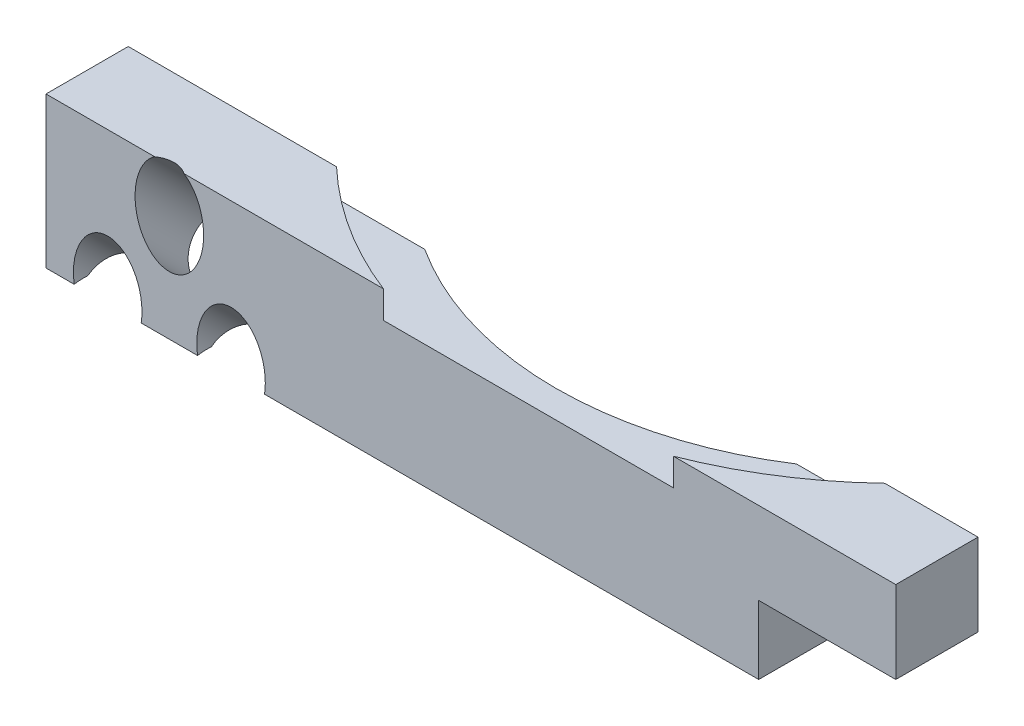
from build123d import *

# Parameters (mm, degrees)
SKETCH_1_W          = 70.4
SKETCH_1_H          = 11
EXTRUDE_1_DEPTH     = 6
CUT_EXTRUDE_1_DEPTH = 6.5
CUT_EXTRUDE_3_DEPTH = 17
CUT_EXTRUDE_4_DEPTH = 2
CUT_EXTRUDE_5_DEPTH = 12
CUT_EXTRUDE_6_DEPTH = 7
SKETCH_11_R         = 2.5
CUT_EXTRUDE_7_DEPTH = 9.52081528


with BuildPart() as part:
    # Эскиз1 → Бобышка-Вытянуть1 (new body)
    with BuildSketch(Plane.XY):
        Rectangle(SKETCH_1_W, SKETCH_1_H)
    extrude(amount=EXTRUDE_1_DEPTH)

    # Эскиз3 → Вырез-Вытянуть1 (cut)
    with BuildSketch(Plane(origin=(0, 5.5, 0), x_dir=(1, 0, 0), z_dir=(0, 1, 0))):
        with BuildLine():
            Line((13.564659966, 0), (-13.564659966, 0))
            ThreePointArc((-13.564659966, 0), (0, -4), (13.564659966, 0))
        make_face()
    extrude(amount=-CUT_EXTRUDE_1_DEPTH, mode=Mode.SUBTRACT)

    # Эскиз6 → Вырез-Вытянуть3 (cut)
    with BuildSketch(Plane.ZY.offset(35.2)):
        Polygon((4.949747468, -5.5), (0, -0.550252532), (0, -5.5), align=None)
    extrude(amount=-CUT_EXTRUDE_3_DEPTH, mode=Mode.SUBTRACT)

    # Эскиз7 → Вырез-Вытянуть4 (cut)
    with BuildSketch(Plane(origin=(0, 5.5, 0), x_dir=(1, 0, 0), z_dir=(0, 1, 0))):
        with BuildLine():
            Line((-13.564659966, 0), (-20, 0))
            ThreePointArc((-20, 0), (-15.583005244, -3.457513111), (-10.583005244, -6))
            Line((-10.583005244, -6), (10.583005244, -6))
            ThreePointArc((10.583005244, -6), (15.583005244, -3.457513111), (20, 0))
            Line((20, 0), (13.564659966, 0))
            ThreePointArc((13.564659966, 0), (0, -4), (-13.564659966, 0))
        make_face()
    extrude(amount=-CUT_EXTRUDE_4_DEPTH, mode=Mode.SUBTRACT)

    # Эскиз9 → Вырез-Вытянуть5 (cut, through all)
    with BuildSketch(Plane(origin=(0, 5.5, 0), x_dir=(1, 0, 0), z_dir=(0, 1, 0))):
        Polygon((26.8, 134.579292019), (26.8, 0), (26.8, -6), (26.8, -140.579292019), (295.958584038, -140.579292019), (295.958584038, 134.579292019), align=None)
    extrude(amount=-CUT_EXTRUDE_5_DEPTH, mode=Mode.SUBTRACT)

    # Эскиз10 → Вырез-Вытянуть6 (cut, through all)
    with BuildSketch(Plane.XY.offset(6)):
        Polygon((16.8, -140.079292019), (16.8, -5.5), (16.8, -0.5), (26.8, -0.5), (161.379292019, -0.5), (348.325311663, -194.142787371), (203.746019644, -333.72207939), align=None)
    extrude(amount=-CUT_EXTRUDE_6_DEPTH, mode=Mode.SUBTRACT)

    # Эскиз11 → Вырез-Вытянуть7 (cut, through all)
    with BuildSketch(Plane(origin=(0, -0.275126266, -0.275126266), x_dir=(1, 0, 0), z_dir=(0, -0.707106781, -0.707106781))):
        with Locations((-26.2, 2.610912703)):
            Circle(SKETCH_11_R)
        with Locations((-30.7, 7.610912703)):
            Circle(SKETCH_11_R)
        with Locations((-21.7, 7.610912703)):
            Circle(SKETCH_11_R)
    extrude(amount=-CUT_EXTRUDE_7_DEPTH, mode=Mode.SUBTRACT)


solid = part.part
